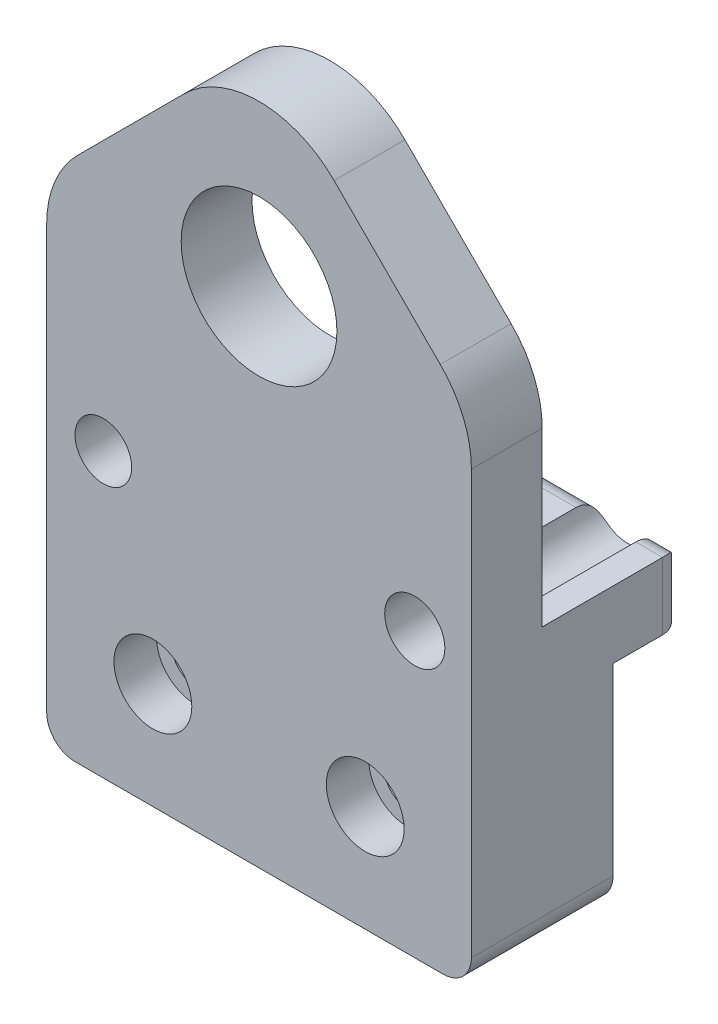
from build123d import *

# Parameters (mm, degrees)
ESBO_O2_R                         = 4
ESBO_O2_R_2                       = 4.25
ESBO_O2_R_3                       = 11
RESSALTO_EXTRUS_O1_DEPTH          = 20
RESSALTO_EXTRUS_O2_DEPTH          = 10
FILETE1_R                         = 3
CORTE_EXTRUS_O1_DEPTH             = 10
REBAIXO_PARA_SHCS_M61_D           = 6.6
REBAIXO_PARA_SHCS_M61_CBORE_D     = 11
REBAIXO_PARA_SHCS_M61_CBORE_DEPTH = 6


with BuildPart() as part:
    # Esboço2 → Ressalto-extrusão1 (new body)
    with BuildSketch(Plane.XY):
        with BuildLine():
            Line((250, 102.212171493), (250, 76.212189341))
            ThreePointArc((250, 76.212189341), (248.828427125, 73.383762216), (246, 72.212189341))
            Line((246, 72.212189341), (194, 72.212189341))
            ThreePointArc((194, 72.212189341), (191.171572875, 73.383762216), (190, 76.212189341))
            Line((190, 76.212189341), (190, 102.212171493))
            Line((190, 102.212171493), (190, 135.998985905))
            ThreePointArc((190, 135.998985905), (191.141807012, 141.73923739), (194.393398282, 146.605587623))
            Line((194.393398282, 146.605587623), (209.393398282, 161.605587623))
            ThreePointArc((209.393398282, 161.605587623), (220, 165.998985905), (230.606601718, 161.605587623))
            Line((230.606601718, 161.605587623), (245.606601718, 146.605587623))
            ThreePointArc((245.606601718, 146.605587623), (248.858192988, 141.73923739), (250, 135.998985905))
            Line((250, 135.998985905), (250, 102.212171493))
        make_face()
        with Locations((198, 112.212189341)):
            Circle(ESBO_O2_R, mode=Mode.SUBTRACT)
        with Locations((242, 112.212189341)):
            Circle(ESBO_O2_R_2, mode=Mode.SUBTRACT)
        with Locations((220, 143.362189341)):
            Circle(ESBO_O2_R_3, mode=Mode.SUBTRACT)
    extrude(amount=RESSALTO_EXTRUS_O1_DEPTH)

    # Esboço3 → Ressalto-extrusão2 (add)
    with BuildSketch(Plane(origin=(0, 0, 0), x_dir=(-1, 0, 0), z_dir=(0, 0, -1))):
        with BuildLine():
            Line((-250, 111.697903626), (-250, 102.212171493))
            Line((-250, 102.212171493), (-190, 102.212171493))
            Line((-190, 102.212171493), (-190, 111.697903626))
            Line((-190, 111.697903626), (-194.033198996, 111.697903626))
            ThreePointArc((-194.033198996, 111.697903626), (-198, 108.212189341), (-201.966801004, 111.697903626))
            Line((-201.966801004, 111.697903626), (-237.781231198, 111.697903626))
            ThreePointArc((-237.781231198, 111.697903626), (-242, 107.962189341), (-246.218768802, 111.697903626))
            Line((-246.218768802, 111.697903626), (-250, 111.697903626))
        make_face()
    extrude(amount=RESSALTO_EXTRUS_O2_DEPTH)

    # Filete1
    filete1_edges = [part.edges().sort_by_distance(p)[0] for p in [
        (219.874016101, 111.697903626, -10),
        (248.109384401, 111.697903626, -10),
        (250, 106.955037559, -10),
        (190, 106.955037559, -10),
        (192.016599498, 111.697903626, -10),
    ]]
    fillet(filete1_edges, radius=FILETE1_R)

    # Esboço4 → Corte-extrusão1 (cut)
    with BuildSketch(Plane(origin=(0, 0, 0), x_dir=(-1, 0, 0), z_dir=(0, 0, -1))):
        with BuildLine():
            Line((-194.033198996, 111.697903626), (-190, 111.697903626))
            Line((-190, 111.697903626), (-190, 135.998985905))
            ThreePointArc((-190, 135.998985905), (-191.141807012, 141.73923739), (-194.393398282, 146.605587623))
            Line((-194.393398282, 146.605587623), (-209.393398282, 161.605587623))
            ThreePointArc((-209.393398282, 161.605587623), (-220, 165.998985905), (-230.606601718, 161.605587623))
            Line((-230.606601718, 161.605587623), (-245.606601718, 146.605587623))
            ThreePointArc((-245.606601718, 146.605587623), (-248.858192988, 141.73923739), (-250, 135.998985905))
            Line((-250, 135.998985905), (-250, 111.697903626))
            Line((-250, 111.697903626), (-246.218768802, 111.697903626))
            ThreePointArc((-246.218768802, 111.697903626), (-242, 116.462189341), (-237.781231198, 111.697903626))
            Line((-237.781231198, 111.697903626), (-201.966801004, 111.697903626))
            ThreePointArc((-201.966801004, 111.697903626), (-198, 116.212189341), (-194.033198996, 111.697903626))
        make_face()
    extrude(amount=-CORTE_EXTRUS_O1_DEPTH, mode=Mode.SUBTRACT)

    # Rebaixo para SHCS M61 (through all)
    with Locations(Plane.XY.offset(20)):
        with Locations((235, 87.212189341), (205, 87.212189341)):
            CounterBoreHole(REBAIXO_PARA_SHCS_M61_D / 2, REBAIXO_PARA_SHCS_M61_CBORE_D / 2, REBAIXO_PARA_SHCS_M61_CBORE_DEPTH)


solid = part.part
